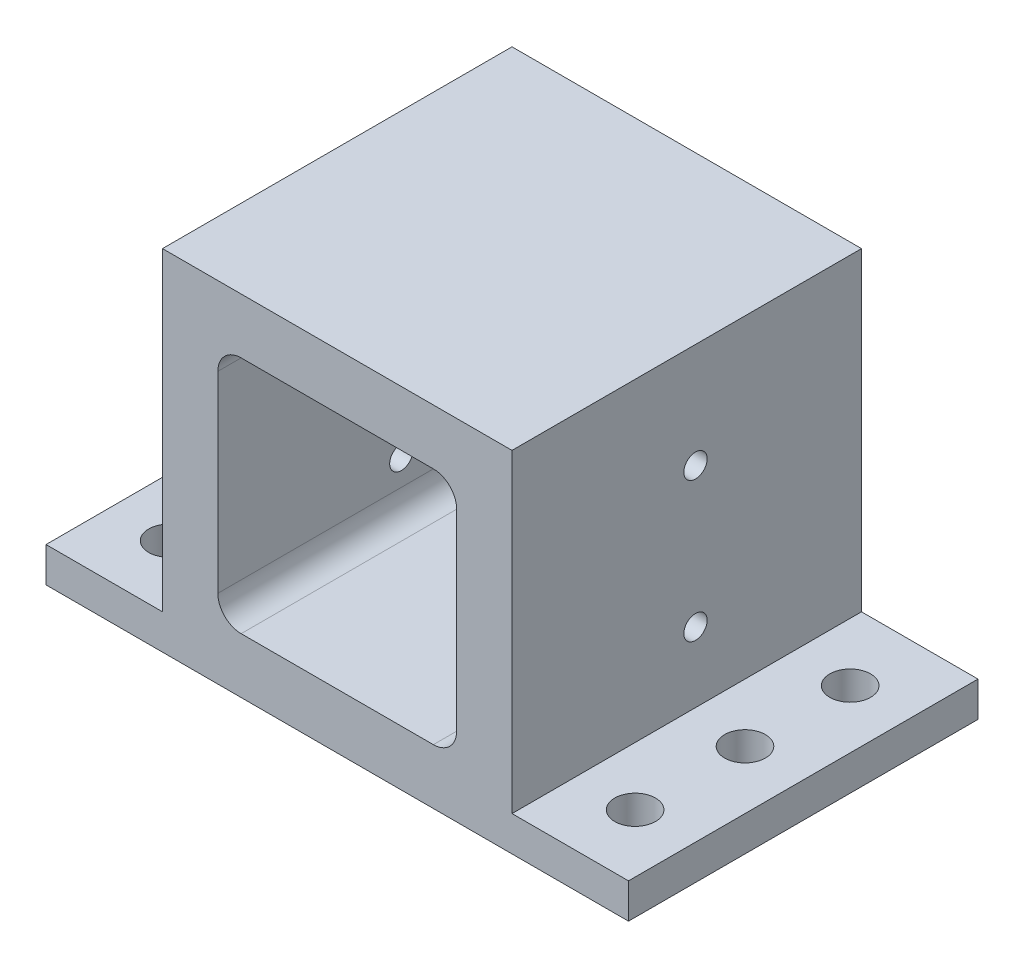
from build123d import *

# Parameters (mm, degrees)
BOSS_EXTRU_1_DEPTH      = 60
ESQUISSE2_W             = 41
ESQUISSE2_H             = 41
ENL_V_MAT_EXTRU_1_DEPTH = 50
CONG_1_R                = 4
ESQUISSE4_R             = 3.5
ENL_V_MAT_EXTRU_2_DEPTH = 61
ESQUISSE6_R             = 2
ENL_V_MAT_EXTRU_4_DEPTH = 81
ESQUISSE7_R             = 1.35
ENL_V_MAT_EXTRU_5_DEPTH = 11


with BuildPart() as part:
    # Esquisse1 → Boss.-Extru.1 (new body)
    with BuildSketch(Plane.XY):
        Polygon((0, 0), (-60, 0), (-60, -54), (-80, -54), (-80, -60), (20, -60), (20, -54), (0, -54), align=None)
    extrude(amount=-BOSS_EXTRU_1_DEPTH)

    # Esquisse2 → Enlèv. mat.-Extru.1 (cut)
    with BuildSketch(Plane.XY):
        with Locations((-30, -30)):
            Rectangle(ESQUISSE2_W, ESQUISSE2_H)
    extrude(amount=-ENL_V_MAT_EXTRU_1_DEPTH, mode=Mode.SUBTRACT)

    # Congé1
    cong_1_edges = [part.edges().sort_by_distance(p)[0] for p in [
        (-50.5, -50.5, -25),
        (-50.5, -9.5, -25),
        (-9.5, -9.5, -25),
        (-9.5, -50.5, -25),
    ]]
    fillet(cong_1_edges, radius=CONG_1_R)

    # Esquisse4 → Enlèv. mat.-Extru.2 (cut, through all)
    with BuildSketch(Plane.XZ.offset(60)):
        with Locations((-70, -11.134276922)):
            Circle(ESQUISSE4_R)
        with Locations((-70, -30)):
            Circle(ESQUISSE4_R)
        with Locations((-70, -48.052106988)):
            Circle(ESQUISSE4_R)
        with Locations((10, -48.052106988)):
            Circle(ESQUISSE4_R)
        with Locations((10, -30)):
            Circle(ESQUISSE4_R)
        with Locations((10, -11.134276922)):
            Circle(ESQUISSE4_R)
    extrude(amount=-ENL_V_MAT_EXTRU_2_DEPTH, mode=Mode.SUBTRACT)

    # Esquisse6 → Enlèv. mat.-Extru.4 (cut, through all)
    with BuildSketch(Plane.ZY.offset(60)):
        with Locations((-31.500403789, -18)):
            Circle(ESQUISSE6_R)
        with Locations((-31.500403789, -42)):
            Circle(ESQUISSE6_R)
    extrude(amount=-ENL_V_MAT_EXTRU_4_DEPTH, mode=Mode.SUBTRACT)

    # Esquisse7 → Enlèv. mat.-Extru.5 (cut, through all)
    with BuildSketch(Plane.XY.offset(-50)):
        with Locations((-30, -17.5)):
            Circle(ESQUISSE7_R)
    extrude(amount=-ENL_V_MAT_EXTRU_5_DEPTH, mode=Mode.SUBTRACT)


solid = part.part
